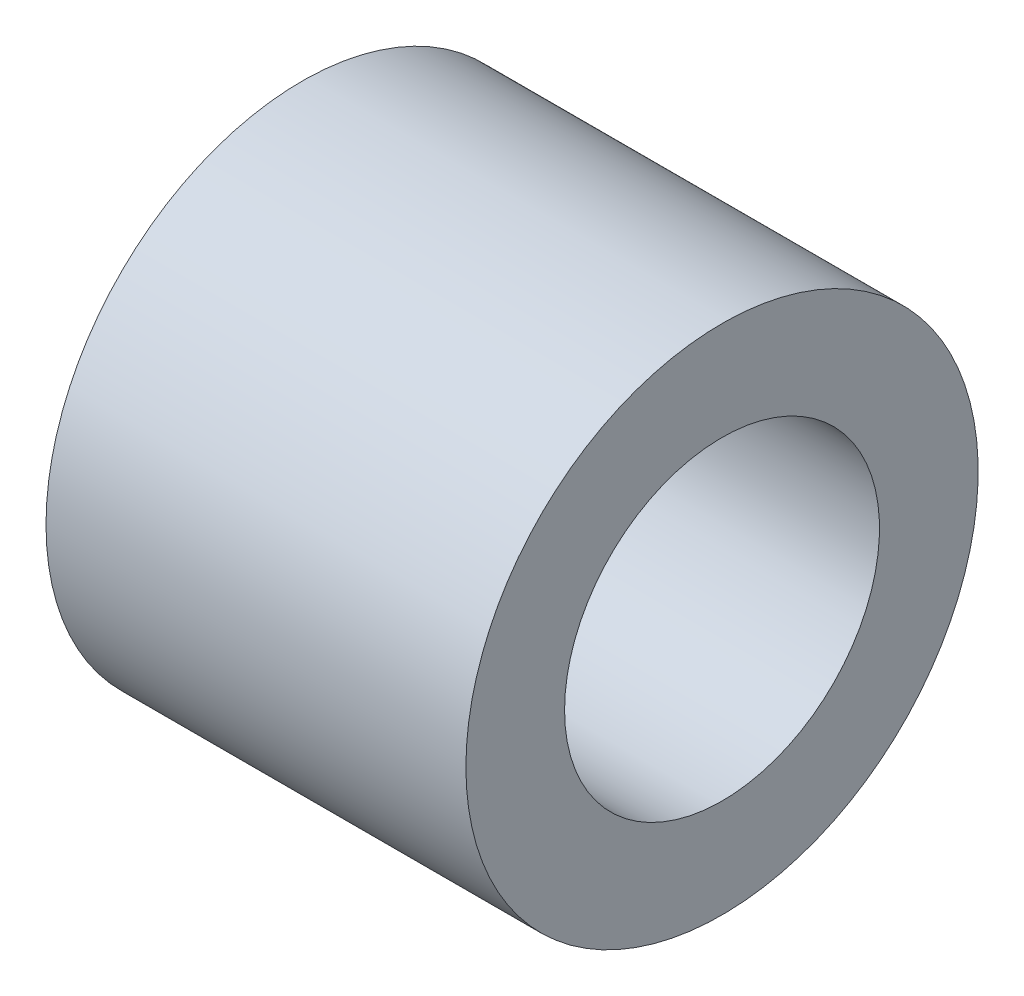
from build123d import *

# Parameters (mm, degrees)
SKETCH1_W = 6.35
SKETCH1_H = 1.49225


with BuildPart() as part:
    # Sketch1 → Revolve1 (revolve)
    with BuildSketch(Plane(origin=(0, 0, 0), x_dir=(1, 0, 0), z_dir=(0, 1, 0))):
        with Locations((3.175, 3.127375)):
            Rectangle(SKETCH1_W, SKETCH1_H)
    revolve(axis=Axis((0, 0, 0), (1, 0, 0)))


solid = part.part
